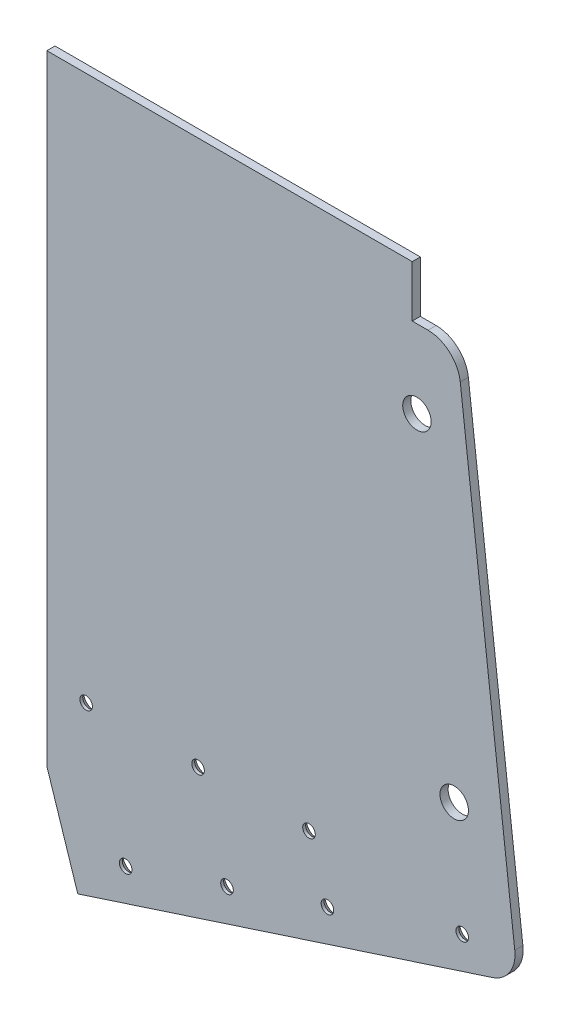
from build123d import *

# Parameters (mm, degrees)
BOSS_EXTRUDE1_DEPTH                           = 3.175
FILLET1_R                                     = 12.7
CUT_EXTRUDE1_DEPTH                            = 4.175
CSK_FOR_8_FLAT_HEAD_MACHINE_SCREW1_AT_2_COUNT = 2
CSK_FOR_8_FLAT_HEAD_MACHINE_SCREW1_AT_2_PITCH = 41.643335968
CSK_FOR_8_FLAT_HEAD_MACHINE_SCREW1_AT_3_COUNT = 2
CSK_FOR_8_FLAT_HEAD_MACHINE_SCREW1_AT_3_PITCH = 55.434622241
CSK_FOR_8_FLAT_HEAD_MACHINE_SCREW1_AT_4_COUNT = 2
CSK_FOR_8_FLAT_HEAD_MACHINE_SCREW1_AT_4_PITCH = 50.008853946
CSK_FOR_8_FLAT_HEAD_MACHINE_SCREW1_AT_5_COUNT = 2
CSK_FOR_8_FLAT_HEAD_MACHINE_SCREW1_AT_5_PITCH = 82.918335968
CSK_FOR_8_FLAT_HEAD_MACHINE_SCREW1_AT_6_COUNT = 2
CSK_FOR_8_FLAT_HEAD_MACHINE_SCREW1_AT_6_PITCH = 86.127052655
CSK_FOR_8_FLAT_HEAD_MACHINE_SCREW1_AT_7_COUNT = 2
CSK_FOR_8_FLAT_HEAD_MACHINE_SCREW1_AT_7_PITCH = 138.300491667
CUT_EXTRUDE2_REACH                            = 5.175
SKETCH5_R                                     = 5.55625


with BuildPart() as part:
    # Sketch1 → Boss-Extrude1 (new body)
    with BuildSketch(Plane.XY):
        Polygon((-234.752967181, 12.7), (-91.997327393, 12.7), (-91.997327393, -7.416979032), (-74.533465131, -7.416979032), (-50.700252483, -210.6746006), (-234.752967181, -270.542758328), align=None)
    extrude(amount=BOSS_EXTRUDE1_DEPTH)

    # Fillet1
    fillet1_edges = [part.edges().sort_by_distance(p)[0] for p in [
        (-74.533465131, -7.416979032, 1.5875),
        (-50.700252483, -210.6746006, 1.5875),
    ]]
    fillet(fillet1_edges, radius=FILLET1_R)

    # Sketch2 → Cut-Extrude1 (cut, through all)
    with BuildSketch(Plane.XY.offset(3.175)):
        Polygon((-234.752967181, -270.542758328), (-222.67581909, -266.614337017), (-234.752967181, -229.485553098), align=None)
    extrude(amount=-CUT_EXTRUDE1_DEPTH, mode=Mode.SUBTRACT)

    # Sketch4 → CSK for #8 Flat Head Machine Screw1 (revolve, cut)
    with BuildSketch(Plane(origin=(-203.96982343, -247.917009556, 0), x_dir=(0, 1, 0), z_dir=(1, 0, 0))):
        Polygon((0, 0), (0, 3.175), (2.45745, 3.175), (2.45745, 2.02344051), (4.2164, 0), align=None)
    csk_for_8_flat_head_machine_screw1 = revolve(axis=Axis((-203.96982343, -247.917009556, -6.35), (0, 0, 1)), mode=Mode.SUBTRACT)

    # CSK for #8 Flat Head Machine Screw1 at 2: CSK for #8 Flat Head Machine Screw1 ×2
    with Locations(*[Vector(0.950956543, 0.309324513, 0) * (i * CSK_FOR_8_FLAT_HEAD_MACHINE_SCREW1_AT_2_PITCH) for i in range(1, CSK_FOR_8_FLAT_HEAD_MACHINE_SCREW1_AT_2_COUNT)]):
        add(csk_for_8_flat_head_machine_screw1, mode=Mode.SUBTRACT)

    # CSK for #8 Flat Head Machine Screw1 at 3: CSK for #8 Flat Head Machine Screw1 ×2
    with Locations(*[Vector(0.510201208, 0.860055072, 0) * (i * CSK_FOR_8_FLAT_HEAD_MACHINE_SCREW1_AT_3_PITCH) for i in range(1, CSK_FOR_8_FLAT_HEAD_MACHINE_SCREW1_AT_3_COUNT)]):
        add(csk_for_8_flat_head_machine_screw1, mode=Mode.SUBTRACT)

    # CSK for #8 Flat Head Machine Screw1 at 4: CSK for #8 Flat Head Machine Screw1 ×2
    with Locations(*[Vector(-0.309324513, 0.950956543, 0) * (i * CSK_FOR_8_FLAT_HEAD_MACHINE_SCREW1_AT_4_PITCH) for i in range(1, CSK_FOR_8_FLAT_HEAD_MACHINE_SCREW1_AT_4_COUNT)]):
        add(csk_for_8_flat_head_machine_screw1, mode=Mode.SUBTRACT)

    # CSK for #8 Flat Head Machine Screw1 at 5: CSK for #8 Flat Head Machine Screw1 ×2
    with Locations(*[Vector(0.950956543, 0.309324513, 0) * (i * CSK_FOR_8_FLAT_HEAD_MACHINE_SCREW1_AT_5_PITCH) for i in range(1, CSK_FOR_8_FLAT_HEAD_MACHINE_SCREW1_AT_5_COUNT)]):
        add(csk_for_8_flat_head_machine_screw1, mode=Mode.SUBTRACT)

    # CSK for #8 Flat Head Machine Screw1 at 6: CSK for #8 Flat Head Machine Screw1 ×2
    with Locations(*[Vector(0.83188266, 0.554951566, 0) * (i * CSK_FOR_8_FLAT_HEAD_MACHINE_SCREW1_AT_6_PITCH) for i in range(1, CSK_FOR_8_FLAT_HEAD_MACHINE_SCREW1_AT_6_COUNT)]):
        add(csk_for_8_flat_head_machine_screw1, mode=Mode.SUBTRACT)

    # CSK for #8 Flat Head Machine Screw1 at 7: CSK for #8 Flat Head Machine Screw1 ×2
    with Locations(*[Vector(0.950956543, 0.309324513, 0) * (i * CSK_FOR_8_FLAT_HEAD_MACHINE_SCREW1_AT_7_PITCH) for i in range(1, CSK_FOR_8_FLAT_HEAD_MACHINE_SCREW1_AT_7_COUNT)]):
        add(csk_for_8_flat_head_machine_screw1, mode=Mode.SUBTRACT)

    # Sketch5 → Cut-Extrude2 (cut, up to next)
    with BuildSketch(Plane.XY.offset(3.175), mode=Mode.PRIVATE) as cut_extrude2_sk1:
        with Locations((-90.146601991, -37.840751583)):
            Circle(SKETCH5_R)
    cut_extrude2_tool1 = extrude(cut_extrude2_sk1.sketch, amount=-CUT_EXTRUDE2_REACH, mode=Mode.PRIVATE) & part.part
    add(cut_extrude2_tool1.solids().sort_by_distance((-90.146602, -37.840752, 3.175))[0], mode=Mode.SUBTRACT)
    # Sketch5 → Cut-Extrude2 (cut, up to next)
    with BuildSketch(Plane.XY.offset(3.175), mode=Mode.PRIVATE) as cut_extrude2_sk2:
        with Locations((-75.576674395, -162.097975039)):
            Circle(SKETCH5_R)
    cut_extrude2_tool2 = extrude(cut_extrude2_sk2.sketch, amount=-CUT_EXTRUDE2_REACH, mode=Mode.PRIVATE) & part.part
    add(cut_extrude2_tool2.solids().sort_by_distance((-75.576674, -162.097975, 3.175))[0], mode=Mode.SUBTRACT)


solid = part.part
